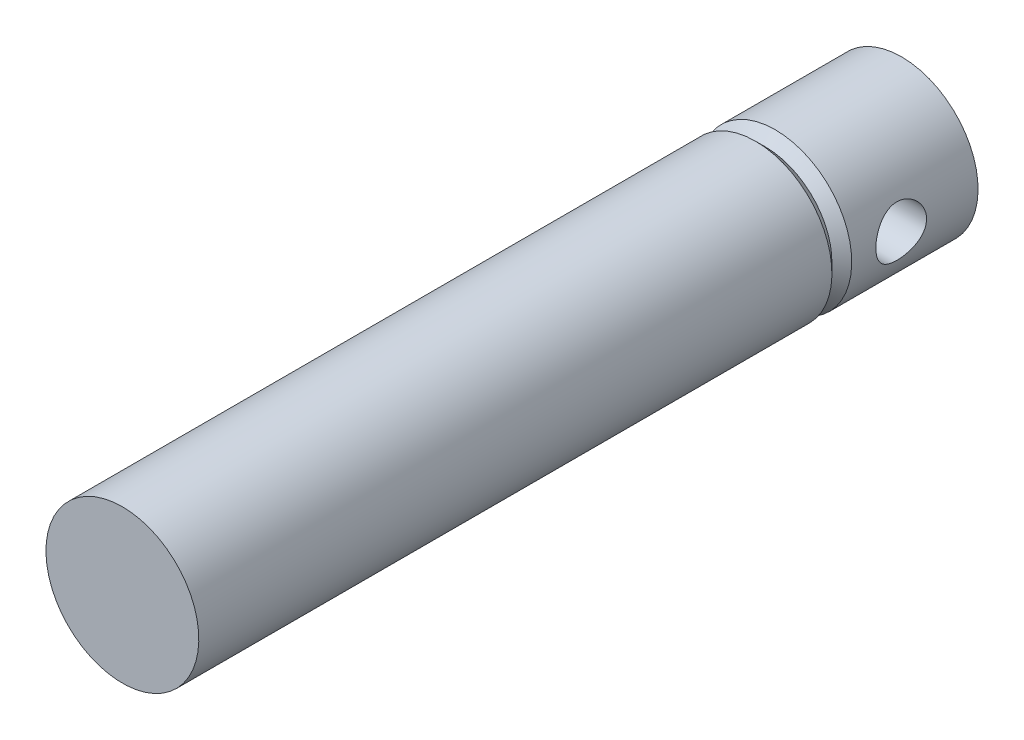
from build123d import *

# Parameters (mm, degrees)
SKETCH2_R                 = 3.2
FRONT_MOUNTING_DEPTH      = 10.65
FRONT_MOUNTING_DEPTH_BACK = 10.65


with BuildPart() as part:
    # Sketch1 → Body (revolve)
    with BuildSketch(Plane(origin=(0, 0, 0), x_dir=(0, 0, -1), z_dir=(1, 0, 0))):
        Polygon((51.45, 9.65), (50.2, 8.4), (48.95, 9.65), (-31, 9.65), (-31, 0), (67.4, 0), (67.4, 9.65), (57.7, 9.65), align=None)
    revolve(axis=Axis((0, 0, -67.4), (0, 0, 1)))

    # Sketch2 → Front-Mounting (cut, two sides)
    with BuildSketch(Plane(origin=(0, 0, 0), x_dir=(0, 0, -1), z_dir=(1, 0, 0))) as front_mounting_sk:
        with Locations((57.7, 0)):
            Circle(SKETCH2_R)
    extrude(amount=FRONT_MOUNTING_DEPTH, mode=Mode.SUBTRACT)
    extrude(front_mounting_sk.sketch, amount=-FRONT_MOUNTING_DEPTH_BACK, mode=Mode.SUBTRACT)


solid = part.part
